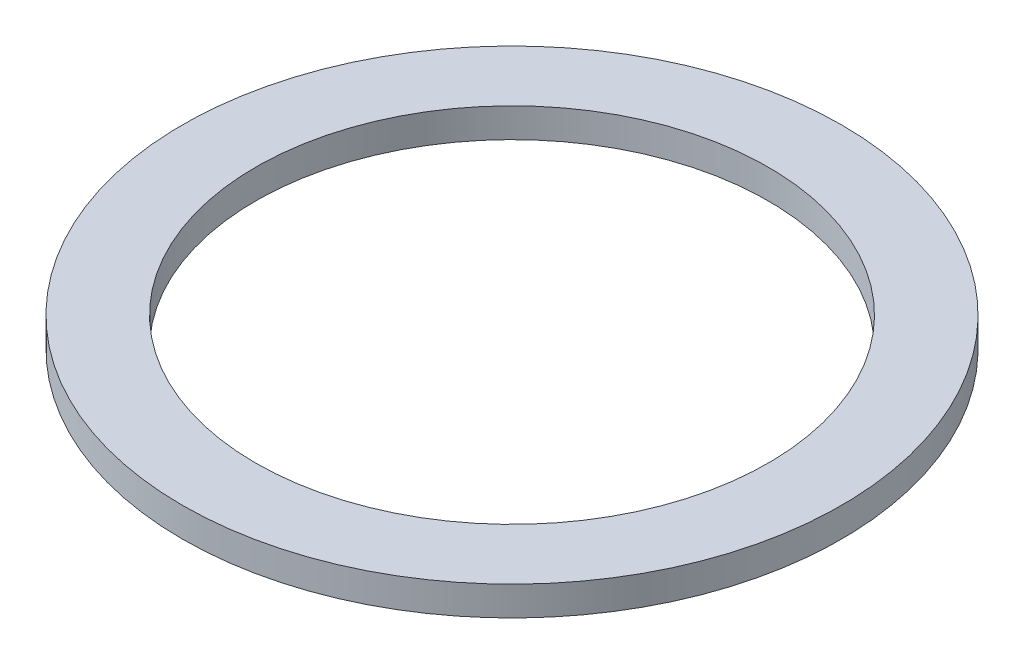
from build123d import *

# Parameters (mm, degrees)
CROQUIS1_R              = 45
CROQUIS1_R_2            = 35
SALIENTE_EXTRUIR1_DEPTH = 4


with BuildPart() as part:
    # Croquis1 → Saliente-Extruir1 (new body)
    with BuildSketch(Plane(origin=(0, 0, 0), x_dir=(1, 0, 0), z_dir=(0, 1, 0))):
        Circle(CROQUIS1_R)
        Circle(CROQUIS1_R_2, mode=Mode.SUBTRACT)
    extrude(amount=SALIENTE_EXTRUIR1_DEPTH)


solid = part.part
